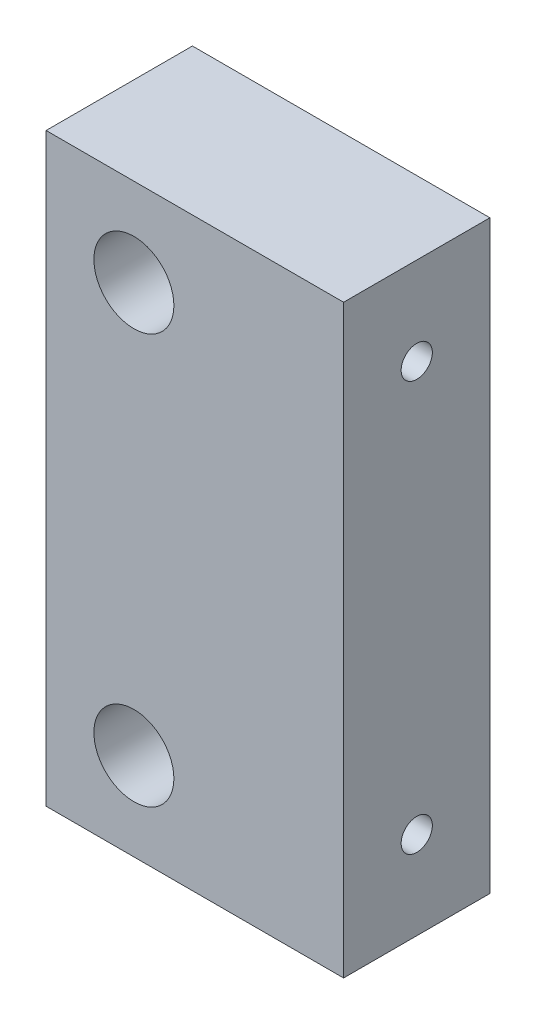
from build123d import *

# Parameters (mm, degrees)
SKETCH1_W           = 30.5
SKETCH1_H           = 15
BOSS_EXTRUDE1_DEPTH = 60
SKETCH2_R           = 4.1
CUT_EXTRUDE1_DEPTH  = 16
SKETCH3_R           = 1.6
CUT_EXTRUDE2_DEPTH  = 15


with BuildPart() as part:
    # Sketch1 → Boss-Extrude1 (new body)
    with BuildSketch(Plane(origin=(0, 0, 0), x_dir=(1, 0, 0), z_dir=(0, 1, 0))):
        Rectangle(SKETCH1_W, SKETCH1_H)
    extrude(amount=BOSS_EXTRUDE1_DEPTH)

    # Sketch2 → Cut-Extrude1 (cut, through all)
    with BuildSketch(Plane.XY.offset(7.5)):
        with Locations((-6.25, 51)):
            Circle(SKETCH2_R)
        with Locations((-6.25, 9)):
            Circle(SKETCH2_R)
    extrude(amount=-CUT_EXTRUDE1_DEPTH, mode=Mode.SUBTRACT)

    # Sketch3 → Cut-Extrude2 (cut)
    with BuildSketch(Plane(origin=(15.25, 0, 0), x_dir=(0, 0, -1), z_dir=(1, 0, 0))):
        with Locations((0, 51)):
            Circle(SKETCH3_R)
        with Locations((0, 9)):
            Circle(SKETCH3_R)
    extrude(amount=-CUT_EXTRUDE2_DEPTH, mode=Mode.SUBTRACT)


solid = part.part
